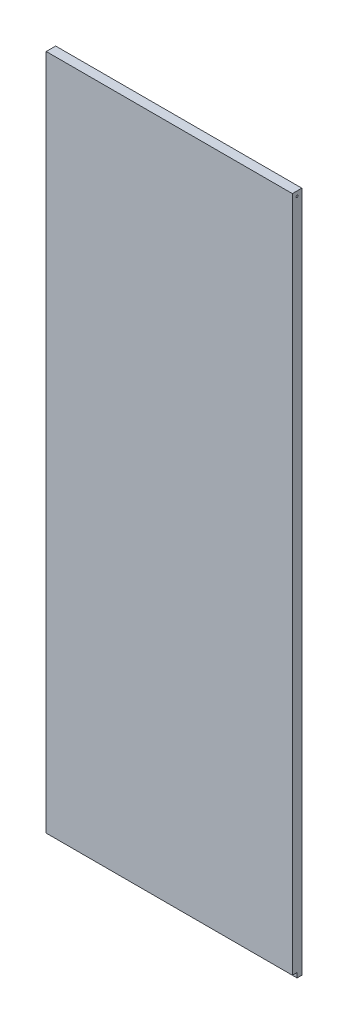
from build123d import *

# Parameters (mm, degrees)
BOSS_EXTRUDE1_DEPTH = 12.7
SKETCH2_W           = 330.2
SKETCH2_H           = 6.35
CUT_EXTRUDE1_DEPTH  = 6.35
SKETCH3_R           = 1.27
CUT_EXTRUDE2_DEPTH  = 331.2


with BuildPart() as part:
    # Sketch1 → Boss-Extrude1 (new body)
    with BuildSketch(Plane.XY):
        Polygon((0, 0), (317.5, 0), (323.85, 0), (323.85, 419.1), (323.85, 914.4), (-6.35, 914.4), (-6.35, 419.1), (-6.35, 0), align=None)
    extrude(amount=BOSS_EXTRUDE1_DEPTH)

    # Sketch2 → Cut-Extrude1 (cut)
    with BuildSketch(Plane.XY.offset(12.7)):
        with Locations((158.75, 3.175)):
            Rectangle(SKETCH2_W, SKETCH2_H)
    extrude(amount=-CUT_EXTRUDE1_DEPTH, mode=Mode.SUBTRACT)

    # Sketch3 → Cut-Extrude2 (cut, through all)
    with BuildSketch(Plane.ZY.offset(6.35)):
        with Locations((6.35, 908.05)):
            Circle(SKETCH3_R)
    extrude(amount=-CUT_EXTRUDE2_DEPTH, mode=Mode.SUBTRACT)


solid = part.part
